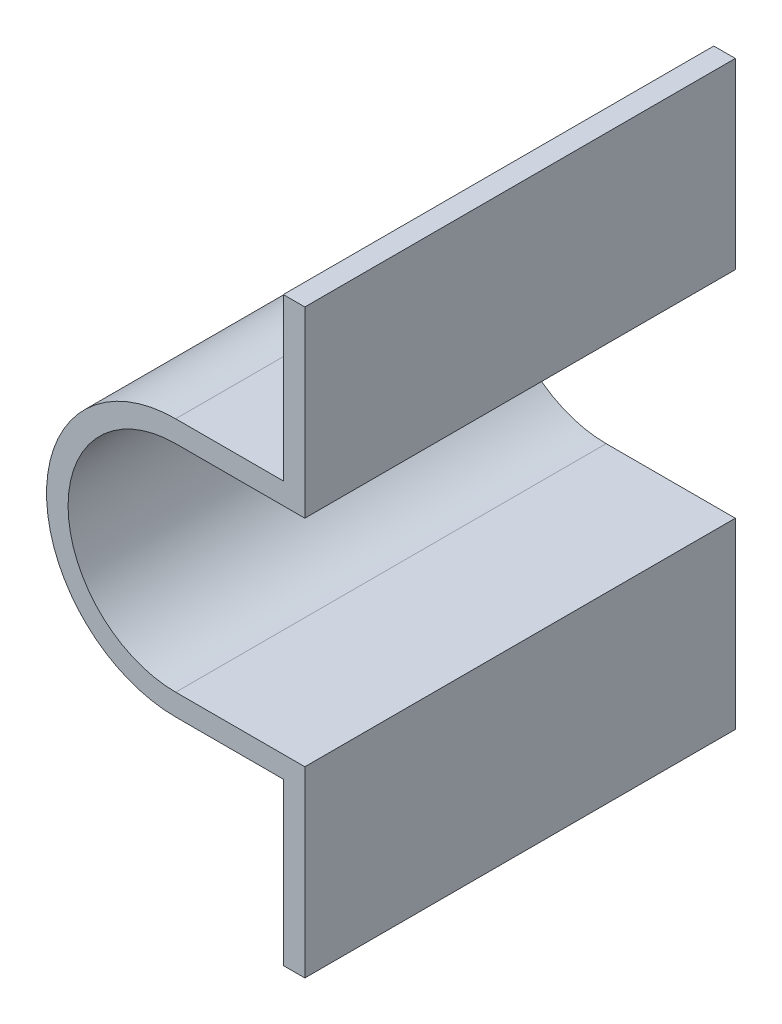
from build123d import *

# Parameters (mm, degrees)
BOSS_EXTRUDE1_DEPTH = 40


with BuildPart() as part:
    # Sketch1 → Boss-Extrude1 (new body)
    with BuildSketch(Plane.XY):
        with BuildLine():
            Line((0, 12), (10, 12))
            Line((10, 12), (10, 27))
            Line((10, 27), (12, 27))
            Line((12, 27), (12, 10))
            Line((12, 10), (0, 10))
            ThreePointArc((0, 10), (-10, 0), (0, -10))
            Line((0, -10), (12, -10))
            Line((12, -10), (12, -27))
            Line((12, -27), (10, -27))
            Line((10, -27), (10, -12))
            Line((10, -12), (0, -12))
            ThreePointArc((0, -12), (-12, 0), (0, 12))
        make_face()
    extrude(amount=BOSS_EXTRUDE1_DEPTH)


solid = part.part
